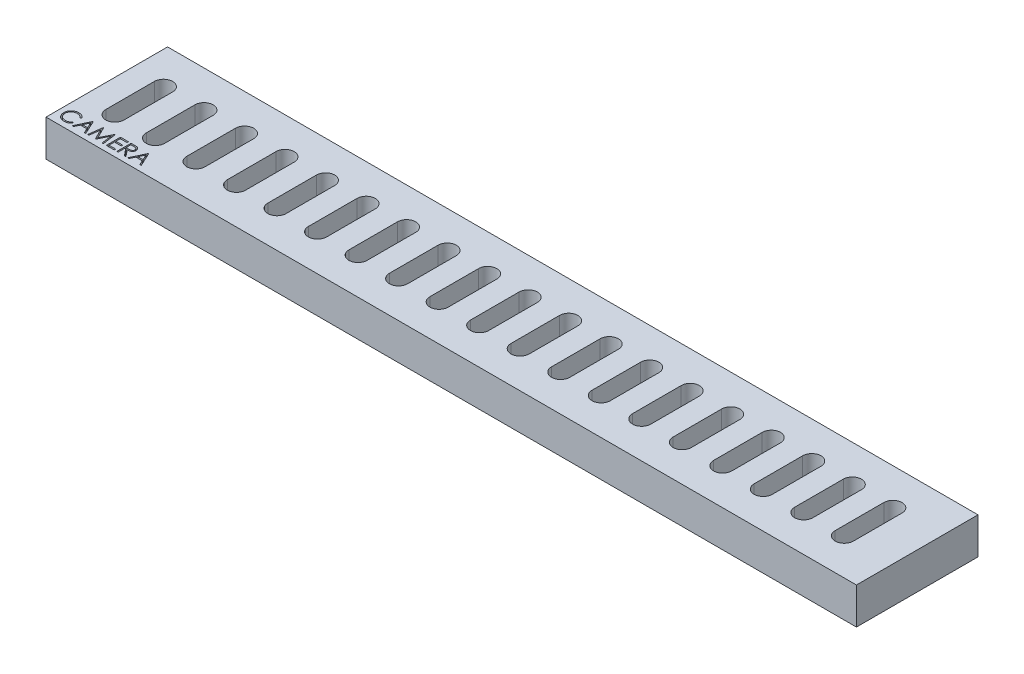
from build123d import *

# Parameters (mm, degrees)
SKETCH2_W           = 200
SKETCH2_H           = 30
BOSS_EXTRUDE1_DEPTH = 9
CUT_EXTRUDE1_DEPTH  = 10
CUT_EXTRUDE2_DEPTH  = 2.5


with BuildPart() as part:
    # Sketch2 → Boss-Extrude1 (new body)
    with BuildSketch(Plane(origin=(0, 0, 0), x_dir=(1, 0, 0), z_dir=(0, 1, 0))):
        with Locations((100, -15)):
            Rectangle(SKETCH2_W, SKETCH2_H)
    extrude(amount=BOSS_EXTRUDE1_DEPTH)

    # Sketch3 → Cut-Extrude1 (cut, through all)
    with BuildSketch(Plane(origin=(0, 9, 0), x_dir=(1, 0, 0), z_dir=(0, 1, 0))):
        with BuildLine():
            Line((10.25, -9), (10.25, -21))
            ThreePointArc((10.25, -21), (8, -23.25), (5.75, -21))
            Line((5.75, -21), (5.75, -9))
            ThreePointArc((5.75, -9), (8, -6.75), (10.25, -9))
        make_face()
        with BuildLine():
            Line((20.25, -9), (20.25, -21))
            ThreePointArc((20.25, -21), (18, -23.25), (15.75, -21))
            Line((15.75, -21), (15.75, -9))
            ThreePointArc((15.75, -9), (18, -6.75), (20.25, -9))
        make_face()
        with BuildLine():
            Line((30.25, -9), (30.25, -21))
            ThreePointArc((30.25, -21), (28, -23.25), (25.75, -21))
            Line((25.75, -21), (25.75, -9))
            ThreePointArc((25.75, -9), (28, -6.75), (30.25, -9))
        make_face()
        with BuildLine():
            Line((40.25, -9), (40.25, -21))
            ThreePointArc((40.25, -21), (38, -23.25), (35.75, -21))
            Line((35.75, -21), (35.75, -9))
            ThreePointArc((35.75, -9), (38, -6.75), (40.25, -9))
        make_face()
        with BuildLine():
            Line((50.25, -9), (50.25, -21))
            ThreePointArc((50.25, -21), (48, -23.25), (45.75, -21))
            Line((45.75, -21), (45.75, -9))
            ThreePointArc((45.75, -9), (48, -6.75), (50.25, -9))
        make_face()
        with BuildLine():
            Line((60.25, -9), (60.25, -21))
            ThreePointArc((60.25, -21), (58, -23.25), (55.75, -21))
            Line((55.75, -21), (55.75, -9))
            ThreePointArc((55.75, -9), (58, -6.75), (60.25, -9))
        make_face()
        with BuildLine():
            Line((70.25, -9), (70.25, -21))
            ThreePointArc((70.25, -21), (68, -23.25), (65.75, -21))
            Line((65.75, -21), (65.75, -9))
            ThreePointArc((65.75, -9), (68, -6.75), (70.25, -9))
        make_face()
        with BuildLine():
            Line((80.25, -9), (80.25, -21))
            ThreePointArc((80.25, -21), (78, -23.25), (75.75, -21))
            Line((75.75, -21), (75.75, -9))
            ThreePointArc((75.75, -9), (78, -6.75), (80.25, -9))
        make_face()
        with BuildLine():
            Line((90.25, -9), (90.25, -21))
            ThreePointArc((90.25, -21), (88, -23.25), (85.75, -21))
            Line((85.75, -21), (85.75, -9))
            ThreePointArc((85.75, -9), (88, -6.75), (90.25, -9))
        make_face()
        with BuildLine():
            Line((100.25, -9), (100.25, -21))
            ThreePointArc((100.25, -21), (98, -23.25), (95.75, -21))
            Line((95.75, -21), (95.75, -9))
            ThreePointArc((95.75, -9), (98, -6.75), (100.25, -9))
        make_face()
        with BuildLine():
            Line((110.25, -9), (110.25, -21))
            ThreePointArc((110.25, -21), (108, -23.25), (105.75, -21))
            Line((105.75, -21), (105.75, -9))
            ThreePointArc((105.75, -9), (108, -6.75), (110.25, -9))
        make_face()
        with BuildLine():
            Line((120.25, -9), (120.25, -21))
            ThreePointArc((120.25, -21), (118, -23.25), (115.75, -21))
            Line((115.75, -21), (115.75, -9))
            ThreePointArc((115.75, -9), (118, -6.75), (120.25, -9))
        make_face()
        with BuildLine():
            Line((130.25, -9), (130.25, -21))
            ThreePointArc((130.25, -21), (128, -23.25), (125.75, -21))
            Line((125.75, -21), (125.75, -9))
            ThreePointArc((125.75, -9), (128, -6.75), (130.25, -9))
        make_face()
        with BuildLine():
            Line((140.25, -9), (140.25, -21))
            ThreePointArc((140.25, -21), (138, -23.25), (135.75, -21))
            Line((135.75, -21), (135.75, -9))
            ThreePointArc((135.75, -9), (138, -6.75), (140.25, -9))
        make_face()
        with BuildLine():
            Line((150.25, -9), (150.25, -21))
            ThreePointArc((150.25, -21), (148, -23.25), (145.75, -21))
            Line((145.75, -21), (145.75, -9))
            ThreePointArc((145.75, -9), (148, -6.75), (150.25, -9))
        make_face()
        with BuildLine():
            Line((160.25, -9), (160.25, -21))
            ThreePointArc((160.25, -21), (158, -23.25), (155.75, -21))
            Line((155.75, -21), (155.75, -9))
            ThreePointArc((155.75, -9), (158, -6.75), (160.25, -9))
        make_face()
        with BuildLine():
            Line((170.25, -9), (170.25, -21))
            ThreePointArc((170.25, -21), (168, -23.25), (165.75, -21))
            Line((165.75, -21), (165.75, -9))
            ThreePointArc((165.75, -9), (168, -6.75), (170.25, -9))
        make_face()
        with BuildLine():
            Line((180.25, -9), (180.25, -21))
            ThreePointArc((180.25, -21), (178, -23.25), (175.75, -21))
            Line((175.75, -21), (175.75, -9))
            ThreePointArc((175.75, -9), (178, -6.75), (180.25, -9))
        make_face()
        with BuildLine():
            Line((190.25, -9), (190.25, -21))
            ThreePointArc((190.25, -21), (188, -23.25), (185.75, -21))
            Line((185.75, -21), (185.75, -9))
            ThreePointArc((185.75, -9), (188, -6.75), (190.25, -9))
        make_face()
    extrude(amount=-CUT_EXTRUDE1_DEPTH, mode=Mode.SUBTRACT)

    # Sketch4 → Cut-Extrude2 (cut)
    with BuildSketch(Plane(origin=(0, 9, 0), x_dir=(1, 0, 0), z_dir=(0, 1, 0))):
        with BuildLine():
            Line((4.638476892, -25.74007119), (4.363637148, -25.950407728))
            add(Edge.make_bspline(
                [(4.363637148, -25.950407728), (4.34403126, -25.927041758), (4.305083813, -25.880624843), (4.242424611, -25.815445298), (4.177122968, -25.754380037), (4.109203847, -25.697138157), (4.037444727, -25.645721391), (3.963583928, -25.597450288), (3.886385883, -25.55418255), (3.779634149, -25.501719564), (3.6399863, -25.446973409), (3.464191461, -25.401070178), (3.280680363, -25.371849002), (3.155482763, -25.368684161), (3.091802212, -25.367074395)],
                knots=[0, 0, 0, 0, 9.1485e-05, 0.000181737, 0.000271024, 0.000359627, 0.000447979, 0.000535687, 0.000624217, 0.000713268, 0.000892422, 0.00107303, 0.001257466, 0.001448389, 0.001448389, 0.001448389, 0.001448389], degree=3))
            add(Edge.make_bspline(
                [(3.091802212, -25.367074395), (3.056718913, -25.367478357), (2.986877921, -25.368282533), (2.883229447, -25.378891658), (2.781516396, -25.393802868), (2.68180493, -25.415928192), (2.584221971, -25.443900811), (2.488129569, -25.477326225), (2.394918969, -25.518681064), (2.303300731, -25.564389324), (2.21552152, -25.616016769), (2.132466472, -25.672330121), (2.054438504, -25.732699218), (1.981375892, -25.797350324), (1.913203944, -25.865992284), (1.850416633, -25.939356626), (1.793231223, -26.017208799), (1.740514198, -26.098522207), (1.693301464, -26.183059999), (1.653771585, -26.271135069), (1.618766463, -26.361239172), (1.59106722, -26.454390333), (1.569142703, -26.549933099), (1.55401504, -26.648123887), (1.543526569, -26.748757566), (1.542726392, -26.816966879), (1.542323046, -26.851349235)],
                knots=[0, 0, 0, 0, 0.000105206, 0.000209435, 0.000312261, 0.00041348, 0.000515565, 0.000616682, 0.000718413, 0.000821258, 0.000923708, 0.001023662, 0.001122111, 0.001219464, 0.00131614, 0.001412112, 0.001508869, 0.001605718, 0.001702691, 0.001799013, 0.001895107, 0.001992482, 0.002090281, 0.00218895, 0.002290387, 0.00239349, 0.00239349, 0.00239349, 0.00239349], degree=3))
            add(Edge.make_bspline(
                [(1.542323046, -26.851349235), (1.543584865, -26.903080554), (1.546062279, -27.004648139), (1.568110613, -27.15341875), (1.601615704, -27.295939424), (1.651831281, -27.431319266), (1.713750332, -27.561227624), (1.791990943, -27.683466477), (1.882607481, -27.799883042), (1.9868819, -27.90772599), (2.101287716, -28.006239715), (2.224035628, -28.092990296), (2.354819916, -28.165305179), (2.492196546, -28.225481125), (2.63722266, -28.271737853), (2.789637462, -28.304301977), (2.949109457, -28.325544157), (3.058078857, -28.327577845), (3.113536988, -28.328612856)],
                knots=[0, 0, 0, 0, 0.000155106, 0.000304531, 0.000450265, 0.000593548, 0.000736853, 0.000881182, 0.001028026, 0.001178769, 0.001330408, 0.001480379, 0.001628835, 0.001777978, 0.001929641, 0.002084627, 0.002245075, 0.00241136, 0.00241136, 0.00241136, 0.00241136], degree=3))
            add(Edge.make_bspline(
                [(3.113536988, -28.328612856), (3.174639677, -28.326924077), (3.294904386, -28.323600154), (3.471272412, -28.295440905), (3.640108178, -28.249782987), (3.801420765, -28.185885065), (3.954755411, -28.102819777), (4.100352071, -28.002121899), (4.238333642, -27.882833567), (4.321304924, -27.791750438), (4.363637148, -27.745279523)],
                knots=[0, 0, 0, 0, 0.00018322, 0.00036062, 0.000534275, 0.000707044, 0.000879893, 0.001056289, 0.001237208, 0.001425665, 0.001425665, 0.001425665, 0.001425665], degree=3))
            Line((4.363637148, -27.745279523), (4.638476892, -27.953512696))
            add(Edge.make_bspline(
                [(4.638476892, -27.953512696), (4.616358782, -27.982051148), (4.572228507, -28.038991354), (4.50077049, -28.119263064), (4.425493192, -28.194767099), (4.345837482, -28.264894721), (4.262719691, -28.331049186), (4.174647378, -28.391351018), (4.082778346, -28.446641902), (3.987423867, -28.497268826), (3.888685254, -28.542186073), (3.786680819, -28.580639841), (3.681850244, -28.613764731), (3.574188735, -28.641016667), (3.463472979, -28.662287751), (3.350102504, -28.676507426), (3.233832629, -28.686249341), (3.155391208, -28.687137256), (3.115640353, -28.687587215)],
                knots=[0, 0, 0, 0, 0.000108293, 0.000216068, 0.000322162, 0.000427957, 0.000534281, 0.00064066, 0.000747915, 0.000855806, 0.000964371, 0.001073102, 0.001182643, 0.001294024, 0.001406092, 0.001520624, 0.001636667, 0.001755891, 0.001755891, 0.001755891, 0.001755891], degree=3))
            add(Edge.make_bspline(
                [(3.115640353, -28.687587215), (3.077996686, -28.687325223), (3.003560996, -28.686807165), (2.893662245, -28.678414997), (2.786672664, -28.666965261), (2.682898038, -28.64972513), (2.581772063, -28.629380789), (2.484211479, -28.602109533), (2.389256268, -28.571560366), (2.297287927, -28.535655379), (2.208228228, -28.495139197), (2.122364416, -28.449347638), (2.039735984, -28.398665773), (1.959530563, -28.344210763), (1.882932979, -28.284233461), (1.809279454, -28.219566827), (1.738156978, -28.150428816), (1.694154293, -28.100573963), (1.672030578, -28.075507888)],
                knots=[0, 0, 0, 0, 0.0001129, 0.000223246, 0.000330481, 0.000435603, 0.000538732, 0.000639764, 0.000739316, 0.000837878, 0.000935767, 0.001032686, 0.001129604, 0.00122645, 0.001323362, 0.001421241, 0.001520399, 0.001620667, 0.001620667, 0.001620667, 0.001620667], degree=3))
            add(Edge.make_bspline(
                [(1.672030578, -28.075507888), (1.636594934, -28.031966699), (1.566151458, -27.945409989), (1.476025774, -27.805124008), (1.398878219, -27.658655799), (1.336502298, -27.50523587), (1.287739565, -27.345208483), (1.25395837, -27.178492968), (1.232006765, -27.005245026), (1.229496476, -26.887408238), (1.228220482, -26.827511093)],
                knots=[0, 0, 0, 0, 0.000168306, 0.00033458, 0.000499224, 0.000664315, 0.00083066, 0.00100034, 0.001174094, 0.001353718, 0.001353718, 0.001353718, 0.001353718], degree=3))
            add(Edge.make_bspline(
                [(1.228220482, -26.827511093), (1.229775675, -26.76455564), (1.232835421, -26.640694715), (1.258831217, -26.458920762), (1.300650013, -26.284769363), (1.360046902, -26.118565619), (1.435352253, -25.959435338), (1.528378867, -25.808594134), (1.638046009, -25.665077334), (1.763493577, -25.531062583), (1.901060912, -25.40852323), (2.048379726, -25.300717026), (2.205161673, -25.21099951), (2.369679525, -25.136003348), (2.543165206, -25.078358885), (2.725248575, -25.038005698), (2.91558749, -25.012888582), (3.045449916, -25.009713374), (3.111433623, -25.008100036)],
                knots=[0, 0, 0, 0, 0.000188789, 0.000371431, 0.000549644, 0.000725278, 0.00089996, 0.001076844, 0.001255917, 0.001440951, 0.001626689, 0.001807878, 0.001987546, 0.002167657, 0.002349462, 0.002534866, 0.002726448, 0.002924344, 0.002924344, 0.002924344, 0.002924344], degree=3))
            add(Edge.make_bspline(
                [(3.111433623, -25.008100036), (3.151648095, -25.008582174), (3.231248592, -25.009536518), (3.349001244, -25.01884266), (3.463643571, -25.034356266), (3.575254553, -25.055472336), (3.68437717, -25.081679658), (3.79017741, -25.115819956), (3.893276097, -25.154856487), (3.993023005, -25.199814953), (4.088939556, -25.250281695), (4.180995874, -25.305697318), (4.268460733, -25.365993124), (4.351949581, -25.430656299), (4.430065792, -25.501054858), (4.505027271, -25.575252454), (4.574288349, -25.655386278), (4.617041544, -25.711791212), (4.638476892, -25.74007119)],
                knots=[0, 0, 0, 0, 0.000120626, 0.000238766, 0.000354085, 0.000467531, 0.000579423, 0.000690512, 0.000800803, 0.000910007, 0.001018518, 0.001125773, 0.001232152, 0.001337058, 0.001442329, 0.001547432, 0.001653292, 0.001759736, 0.001759736, 0.001759736, 0.001759736], degree=3))
        make_face()
        Polygon((6.792323046, -25.097843626), (8.407707661, -28.597843626), (8.066261347, -28.597843626), (7.548833462, -27.476048754), (5.962194841, -27.476048754), (5.430043398, -28.597843626), (5.087194841, -28.597843626), (6.747451251, -25.097843626), align=None)
        Polygon((6.766381539, -25.780035132), (6.132567437, -27.117074395), (7.383368719, -27.117074395), align=None, mode=Mode.SUBTRACT)
        Polygon((8.85642561, -28.597843626), (9.318464873, -25.097843626), (9.363336668, -25.097843626), (10.808348687, -27.969638497), (12.249855097, -25.097843626), (12.295428014, -25.097843626), (12.760271764, -28.597843626), (12.444766956, -28.597843626), (12.109630738, -26.079414138), (10.846209264, -28.597843626), (10.775395962, -28.597843626), (9.507066636, -26.073805164), (9.172631539, -28.597843626), align=None)
        Polygon((13.478220482, -25.097843626), (15.452579456, -25.097843626), (15.452579456, -25.456817985), (13.792323046, -25.456817985), (13.792323046, -26.533741061), (15.452579456, -26.533741061), (15.452579456, -26.89271542), (13.792323046, -26.89271542), (13.792323046, -28.238869267), (15.452579456, -28.238869267), (15.452579456, -28.597843626), (13.478220482, -28.597843626), align=None)
        with BuildLine():
            Line((16.080784584, -25.097843626), (16.781205257, -25.097843626))
            add(Edge.make_bspline(
                [(16.781205257, -25.097843626), (16.827946386, -25.097999212), (16.91769453, -25.098297954), (17.046267801, -25.099963717), (17.163094898, -25.104738072), (17.268114737, -25.108846656), (17.361325392, -25.116338597), (17.443012683, -25.123499244), (17.51280038, -25.132872905), (17.555046231, -25.141578328), (17.574174007, -25.145519908)],
                knots=[0, 0, 0, 0, 0.000140226, 0.00026925, 0.000385712, 0.000490995, 0.000584507, 0.000666202, 0.000736998, 0.000795574, 0.000795574, 0.000795574, 0.000795574], degree=3))
            add(Edge.make_bspline(
                [(17.574174007, -25.145519908), (17.599780631, -25.151846673), (17.650447621, -25.164365237), (17.723397687, -25.190824837), (17.792912011, -25.221444462), (17.858701835, -25.257408182), (17.920437626, -25.298982962), (17.978755937, -25.345451084), (18.033921401, -25.39655829), (18.083703031, -25.453593132), (18.130642082, -25.513429641), (18.170230709, -25.578133398), (18.204357189, -25.645794926), (18.231527706, -25.717102344), (18.253405679, -25.791364115), (18.268831919, -25.869252912), (18.278083106, -25.950413887), (18.279024962, -26.005771796), (18.279502533, -26.033841222)],
                knots=[0, 0, 0, 0, 7.9081e-05, 0.000156475, 0.000232432, 0.000306798, 0.00038108, 0.000455429, 0.000530331, 0.000606314, 0.000682321, 0.000758201, 0.000833453, 0.000909362, 0.000986794, 0.001065445, 0.001147284, 0.001231465, 0.001231465, 0.001231465, 0.001231465], degree=3))
            add(Edge.make_bspline(
                [(18.279502533, -26.033841222), (18.278033535, -26.080476326), (18.275167139, -26.171473494), (18.248442035, -26.303534376), (18.204665516, -26.42672369), (18.144342227, -26.540886328), (18.067522751, -26.643796974), (17.97519796, -26.734187429), (17.867316348, -26.809827341), (17.766887032, -26.862280146), (17.678172833, -26.895873055), (17.60513952, -26.919509414), (17.525472542, -26.937771379), (17.439935208, -26.954131511), (17.348171552, -26.966483205), (17.250401513, -26.9755298), (17.146555361, -26.981183848), (17.075216292, -26.982025853), (17.038516956, -26.98245901)],
                knots=[0, 0, 0, 0, 0.000139777, 0.000272741, 0.000402249, 0.000530843, 0.000658588, 0.000786009, 0.000916741, 0.001052522, 0.001124656, 0.001201155, 0.001282612, 0.001369656, 0.001462366, 0.001560247, 0.001664165, 0.001774261, 0.001774261, 0.001774261, 0.001774261], degree=3))
            Line((17.038516956, -26.98245901), (18.324374328, -28.597843626))
            Line((18.324374328, -28.597843626), (17.935952853, -28.597843626))
            Line((17.935952853, -28.597843626), (16.650095482, -26.98245901))
            Line((16.650095482, -26.98245901), (16.394887148, -26.98245901))
            Line((16.394887148, -26.98245901), (16.394887148, -28.597843626))
            Line((16.394887148, -28.597843626), (16.080784584, -28.597843626))
            Line((16.080784584, -28.597843626), (16.080784584, -25.097843626))
        make_face()
        with BuildLine():
            Line((16.394887148, -25.456817985), (16.394887148, -26.623484651))
            Line((16.394887148, -26.623484651), (17.035712469, -26.628392504))
            add(Edge.make_bspline(
                [(17.035712469, -26.628392504), (17.065632508, -26.62840574), (17.123626065, -26.628431397), (17.20752673, -26.624437621), (17.285646841, -26.619894302), (17.357687594, -26.612944957), (17.423681169, -26.603988885), (17.483594582, -26.592785901), (17.537525634, -26.579733838), (17.600424172, -26.559532212), (17.670660704, -26.527526194), (17.746992164, -26.480960695), (17.811994501, -26.422391576), (17.866912364, -26.35541812), (17.911041795, -26.281781871), (17.94215385, -26.202365502), (17.961896292, -26.119173904), (17.964224837, -26.061995796), (17.965399969, -26.0331401)],
                knots=[0, 0, 0, 0, 8.9746e-05, 0.000173954, 0.000251933, 0.000324488, 0.000391021, 0.000451663, 0.000507268, 0.000557378, 0.000649639, 0.000738152, 0.000824558, 0.000910739, 0.000997194, 0.001080909, 0.00116578, 0.001252248, 0.001252248, 0.001252248, 0.001252248], degree=3))
            add(Edge.make_bspline(
                [(17.965399969, -26.0331401), (17.964197848, -26.004993526), (17.961815682, -25.949217287), (17.942366914, -25.867561377), (17.909477533, -25.790494427), (17.865155295, -25.718329942), (17.81115614, -25.652824206), (17.747838327, -25.596777053), (17.676933132, -25.550527588), (17.610661933, -25.520973208), (17.551427721, -25.502853355), (17.499998061, -25.490102191), (17.441886583, -25.479857722), (17.376811125, -25.471649661), (17.305049494, -25.464594717), (17.226238843, -25.459842938), (17.140902062, -25.457029074), (17.081755131, -25.456889985), (17.051137148, -25.456817985)],
                knots=[0, 0, 0, 0, 8.4371e-05, 0.000167192, 0.000250141, 0.000334794, 0.000420435, 0.000503871, 0.000587493, 0.000673488, 0.0007205, 0.000773215, 0.000832351, 0.0008974, 0.000969955, 0.001048634, 0.001134217, 0.001226067, 0.001226067, 0.001226067, 0.001226067], degree=3))
            Line((17.051137148, -25.456817985), (16.394887148, -25.456817985))
        make_face(mode=Mode.SUBTRACT)
        Polygon((20.478220482, -25.097843626), (22.093605097, -28.597843626), (21.752158783, -28.597843626), (21.234730898, -27.476048754), (19.648092277, -27.476048754), (19.115940834, -28.597843626), (18.773092277, -28.597843626), (20.433348687, -25.097843626), align=None)
        Polygon((20.452278975, -25.780035132), (19.818464873, -27.117074395), (21.069266155, -27.117074395), align=None, mode=Mode.SUBTRACT)
    extrude(amount=-CUT_EXTRUDE2_DEPTH, mode=Mode.SUBTRACT)


solid = part.part
